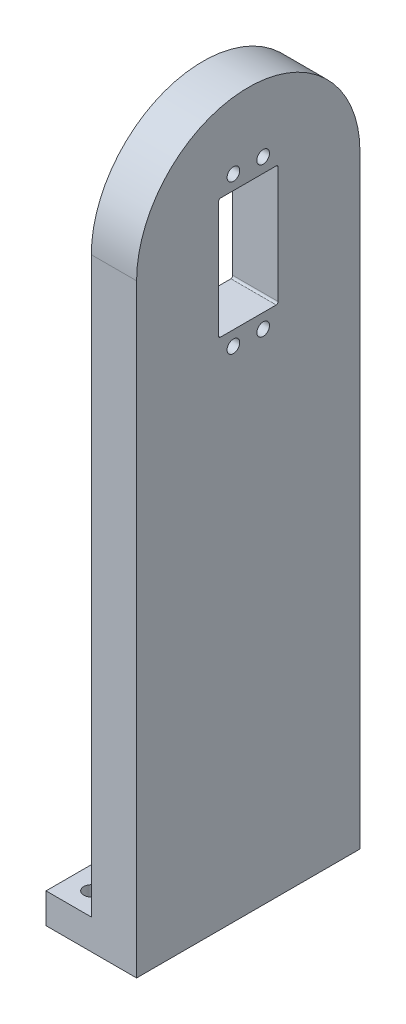
from build123d import *

# Parameters (mm, degrees)
BOSS_EXTRUDE1_DEPTH = 15
CUT_EXTRUDE2_DEPTH  = 15
SKETCH4_W           = 15
SKETCH4_H           = 74
BOSS_EXTRUDE2_DEPTH = 10
SKETCH5_R           = 2.5
CUT_EXTRUDE3_DEPTH  = 10
SKETCH6_R           = 2.1
CUT_EXTRUDE4_DEPTH  = 16


with BuildPart() as part:
    # Sketch1 → Boss-Extrude1 (new body)
    with BuildSketch(Plane(origin=(0, 0, 0), x_dir=(0, 0, -1), z_dir=(1, 0, 0))):
        with BuildLine():
            Line((-37, 0), (-37, -200))
            Line((-37, -200), (37, -200))
            Line((37, -200), (37, 0))
            ThreePointArc((37, 0), (0, 37), (-37, 0))
        make_face()
    extrude(amount=BOSS_EXTRUDE1_DEPTH)

    # Sketch3 → Cut-Extrude2 (cut)
    with BuildSketch(Plane(origin=(15, 0, 0), x_dir=(0, 0, -1), z_dir=(1, 0, 0))):
        with BuildLine():
            Line((9.845321657, 9.230794756), (9.85, -29.35))
            ThreePointArc((9.85, -29.35), (9.672784276, -29.815555418), (9.230794756, -30.045321657))
            Line((9.230794756, -30.045321657), (-9.230794756, -30.045321657))
            ThreePointArc((-9.230794756, -30.045321657), (-9.665330895, -29.865330895), (-9.845321657, -29.430794756))
            Line((-9.845321657, -29.430794756), (-9.845321657, 9.230794756))
            ThreePointArc((-9.845321657, 9.230794756), (-9.665330895, 9.665330895), (-9.230794756, 9.845321657))
            Line((-9.230794756, 9.845321657), (9.230794756, 9.845321657))
            ThreePointArc((9.230794756, 9.845321657), (9.665330895, 9.665330895), (9.845321657, 9.230794756))
        make_face()
    extrude(amount=-CUT_EXTRUDE2_DEPTH, mode=Mode.SUBTRACT)

    # Sketch4 → Boss-Extrude2 (add)
    with BuildSketch(Plane.XZ.offset(200)):
        with Locations((-7.5, 0)):
            Rectangle(SKETCH4_W, SKETCH4_H)
    extrude(amount=-BOSS_EXTRUDE2_DEPTH)

    # Sketch5 → Cut-Extrude3 (cut)
    with BuildSketch(Plane(origin=(0, -190, 0), x_dir=(1, 0, 0), z_dir=(0, 1, 0))):
        with Locations((-7.5, 29.5)):
            Circle(SKETCH5_R)
        with Locations((-7.5, -29.5)):
            Circle(SKETCH5_R)
    extrude(amount=-CUT_EXTRUDE3_DEPTH, mode=Mode.SUBTRACT)

    # Sketch6 → Cut-Extrude4 (cut, through all)
    with BuildSketch(Plane.ZY):
        with Locations((4.925, 14.611145618)):
            Circle(SKETCH6_R)
        with Locations((-4.925, 14.611145618)):
            Circle(SKETCH6_R)
        with Locations((4.925, -34.811145618)):
            Circle(SKETCH6_R)
        with Locations((-4.925, -34.811145618)):
            Circle(SKETCH6_R)
    extrude(amount=-CUT_EXTRUDE4_DEPTH, mode=Mode.SUBTRACT)


solid = part.part
